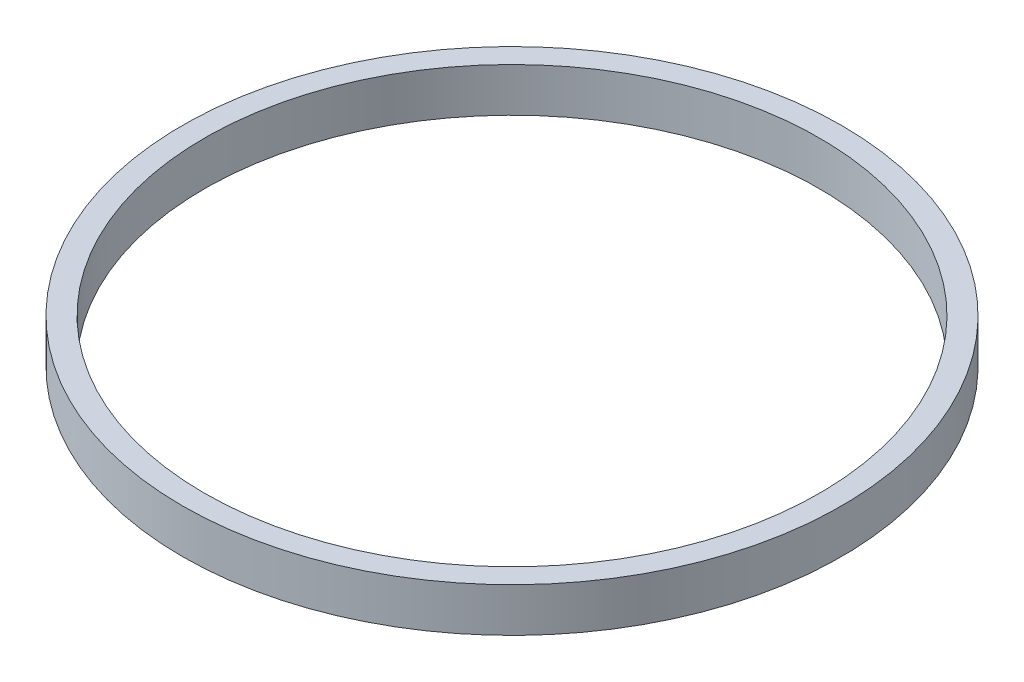
from build123d import *

# Parameters (mm, degrees)
SKETCH1_R               = 225
BOSS_EXTRUDE1_DEPTH     = 30
SKETCH2_R               = 210
CUT_EXTRUDE1_DEPTH      = 1
CUT_EXTRUDE1_DEPTH_BACK = 31


with BuildPart() as part:
    # Sketch1 → Boss-Extrude1 (new body)
    with BuildSketch(Plane(origin=(0, 0, 0), x_dir=(1, 0, 0), z_dir=(0, 1, 0))):
        Circle(SKETCH1_R)
    extrude(amount=BOSS_EXTRUDE1_DEPTH)

    # Sketch2 → Cut-Extrude1 (cut, two sides)
    with BuildSketch(Plane(origin=(0, 30, 0), x_dir=(1, 0, 0), z_dir=(0, 1, 0))) as cut_extrude1_sk:
        Circle(SKETCH2_R)
    extrude(amount=CUT_EXTRUDE1_DEPTH, mode=Mode.SUBTRACT)
    extrude(cut_extrude1_sk.sketch, amount=-CUT_EXTRUDE1_DEPTH_BACK, mode=Mode.SUBTRACT)


solid = part.part
